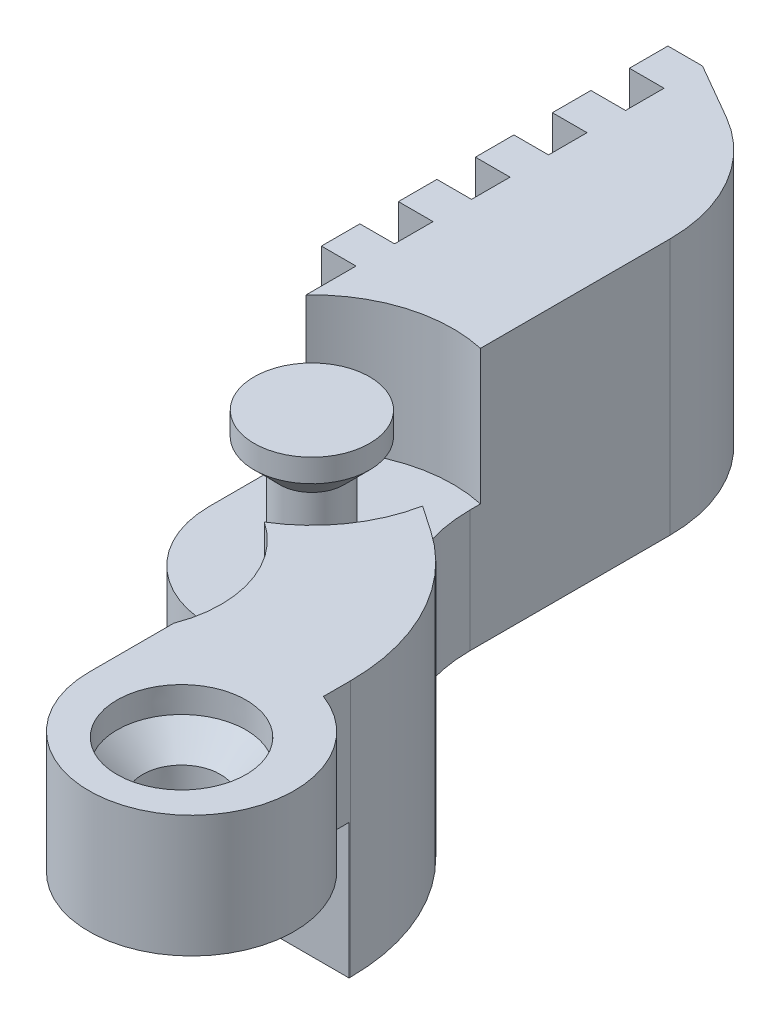
from build123d import *

# Parameters (mm, degrees)
BOSS_EXTRUDE1_DEPTH     = 20
SKETCH2_W               = 19.610643165
SKETCH2_H               = 11
CUT_EXTRUDE1_DEPTH      = 227.167829004
CUT_EXTRUDE1_DEPTH_BACK = 227.167829004
SKETCH7_R               = 11
CUT_EXTRUDE2_DEPTH      = 10.5
SKETCH6_W               = 2.5
SKETCH6_H               = 6.937111225


with BuildPart() as part:
    # Sketch1 → Boss-Extrude1 (new body)
    with BuildSketch(Plane(origin=(0, 0, 0), x_dir=(1, 0, 0), z_dir=(0, 1, 0))):
        with BuildLine():
            Line((-14.599777392, -163.687024017), (-14.599777392, -179.289222575))
            ThreePointArc((-14.599777392, -179.289222575), (-13.212758245, -184.889636615), (-9.372337822, -189.195403737))
            Line((-9.372337822, -189.195403737), (-4.197358995, -192.733382325))
            ThreePointArc((-4.197358995, -192.733382325), (0.923201568, -198.474405155), (2.772560431, -205.941623874))
            Line((2.772560431, -205.941623874), (2.772560431, -208.068159927))
            ThreePointArc((2.772560431, -208.068159927), (4.572718915, -222.13666845), (-8, -215.572352665))
            Line((-8, -215.572352665), (-8, -208.969123671))
            ThreePointArc((-8, -208.969123671), (-9.205712947, -200.564063539), (-17, -197.195403737))
            ThreePointArc((-17, -197.195403737), (-22.656854249, -194.852257987), (-25, -189.195403737))
            Line((-25, -189.195403737), (-25, -177.754249464))
            Line((-25, -177.754249464), (-27.7, -177.754249464))
            Line((-27.7, -177.754249464), (-27.7, -174.754249464))
            Line((-27.7, -174.754249464), (-25, -174.754249464))
            Line((-25, -174.754249464), (-25, -171.754249464))
            Line((-25, -171.754249464), (-27.7, -171.754249464))
            Line((-27.7, -171.754249464), (-27.7, -168.754249464))
            Line((-27.7, -168.754249464), (-25, -168.754249464))
            Line((-25, -168.754249464), (-25, -165.754249464))
            Line((-25, -165.754249464), (-27.7, -165.754249464))
            Line((-27.7, -165.754249464), (-27.7, -162.754249464))
            Line((-27.7, -162.754249464), (-25, -162.754249464))
            Line((-25, -162.754249464), (-25, -159.754249464))
            Line((-25, -159.754249464), (-27.7, -159.754249464))
            Line((-27.7, -159.754249464), (-27.7, -156.754249464))
            Line((-27.7, -156.754249464), (-25, -156.754249464))
            Line((-25, -156.754249464), (-25, -153.754249464))
            Line((-25, -153.754249464), (-27.7, -153.754249464))
            Line((-27.7, -153.754249464), (-27.7, -150.754249464))
            Line((-27.7, -150.754249464), (-25, -150.754249464))
            Line((-25, -150.754249464), (-20.599777392, -153.294719172))
            ThreePointArc((-20.599777392, -153.294719172), (-16.207472546, -157.687024017), (-14.599777392, -163.687024017))
        make_face()
    extrude(amount=BOSS_EXTRUDE1_DEPTH)

    # Sketch2 → Cut-Extrude1 (cut, two sides)
    with BuildSketch(Plane(origin=(0, 0, 0), x_dir=(0, 0, -1), z_dir=(1, 0, 0))) as cut_extrude1_sk:
        with Locations((-215.877674248, 5)):
            Rectangle(SKETCH2_W, SKETCH2_H)
    extrude(amount=CUT_EXTRUDE1_DEPTH, mode=Mode.SUBTRACT)
    extrude(cut_extrude1_sk.sketch, amount=-CUT_EXTRUDE1_DEPTH_BACK, mode=Mode.SUBTRACT)

    # Sketch4 → Cut-Revolve8 (revolve, cut)
    with BuildSketch(Plane(origin=(0, 0, 0), x_dir=(0, 0, -1), z_dir=(1, 0, 0)), mode=Mode.PRIVATE) as cut_revolve8_sk:
        Polygon((-213.371823115, 3.99935592), (-216.352696282, 4.00886504), (-216.352696282, 9.999898237), (-216.352696282, 21.744358227), (-211.315205583, 21.744358227), (-211.327201493, 17.983937872), (-213.333571374, 15.990328105), (-213.352711547, 9.990358634), align=None)
    revolve(cut_revolve8_sk.sketch.rotate(Axis((0, 4.00886504, 216.352696282), (0, 1, 0)), 180), axis=Axis((0, 4.00886504, 216.352696282), (0, 1, 0)), mode=Mode.SUBTRACT)

    # Sketch7 → Cut-Extrude2 (cut)
    with BuildSketch(Plane(origin=(0, 20, 0), x_dir=(1, 0, 0), z_dir=(0, 1, 0))):
        with Locations((-17, -189.195403737)):
            Circle(SKETCH7_R)
    extrude(amount=-CUT_EXTRUDE2_DEPTH, mode=Mode.SUBTRACT)

    # Sketch6 → Revolve2 (revolve)
    with BuildSketch(Plane.XY.offset(189.195403737)):
        Polygon((-17, 10), (-14.5, 10), (-14.5, 16.207106781), (-12.5, 18.207106781), (-12.5, 20), (-17, 20), align=None)
        with Locations((-15.75, 6.531444388)):
            Rectangle(SKETCH6_W, SKETCH6_H)
        Polygon((-14, 16), (-14, 10), (-9, 10), (-9, 20), (-12, 20), (-12, 18), align=None)
    revolve(axis=Axis((-17, 0, 189.195403737), (0, 1, 0)))


with BuildPart() as revolve2_kept_piece:
    # of the separate pieces the step leaves, the one the design keeps (revolve2_pieces_kept)
    add(part.part.solids().sort_by_distance((-25, 0, 189.195403737))[0])


solid = revolve2_kept_piece.part
